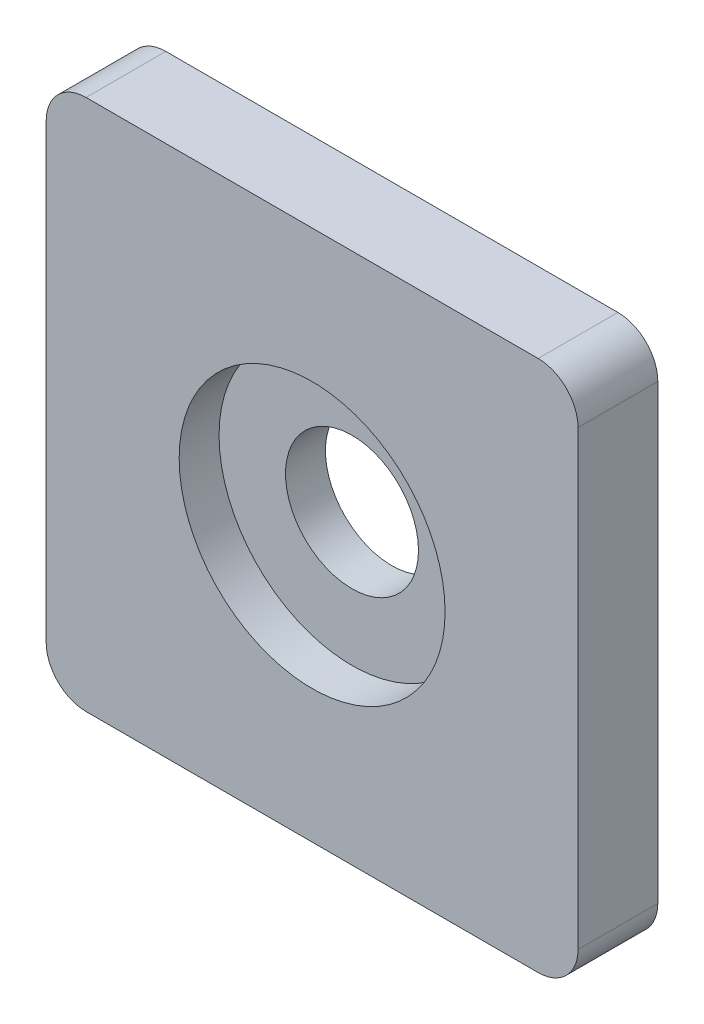
from build123d import *

# Parameters (mm, degrees)
ESQUISSE1_R             = 2.5
BOSS_EXTRU_1_DEPTH      = 1.5
ENL_V_START             = -1.5
ESQUISSE2_R             = 5
ENL_V_MAT_EXTRU_1_DEPTH = 1.5


with BuildPart() as part:
    # Esquisse1 → Boss.-Extru.1 (new body, symmetric)
    with BuildSketch(Plane.XY):
        with BuildLine():
            Line((-8.5, -10), (8.5, -10))
            ThreePointArc((8.5, -10), (9.560660172, -9.560660172), (10, -8.5))
            Line((10, -8.5), (10, 8.5))
            ThreePointArc((10, 8.5), (9.560660172, 9.560660172), (8.5, 10))
            Line((8.5, 10), (-8.5, 10))
            ThreePointArc((-8.5, 10), (-9.560660172, 9.560660172), (-10, 8.5))
            Line((-10, 8.5), (-10, -8.5))
            ThreePointArc((-10, -8.5), (-9.560660172, -9.560660172), (-8.5, -10))
        make_face()
        Circle(ESQUISSE1_R, mode=Mode.SUBTRACT)
    extrude(amount=BOSS_EXTRU_1_DEPTH, both=True)

    # Esquisse2 → Enlèv. mat.-Extru.1 (cut)
    with BuildSketch(Plane.XY.offset(1.5).offset(ENL_V_START)):
        Circle(ESQUISSE2_R)
    extrude(amount=ENL_V_MAT_EXTRU_1_DEPTH, mode=Mode.SUBTRACT)


solid = part.part
